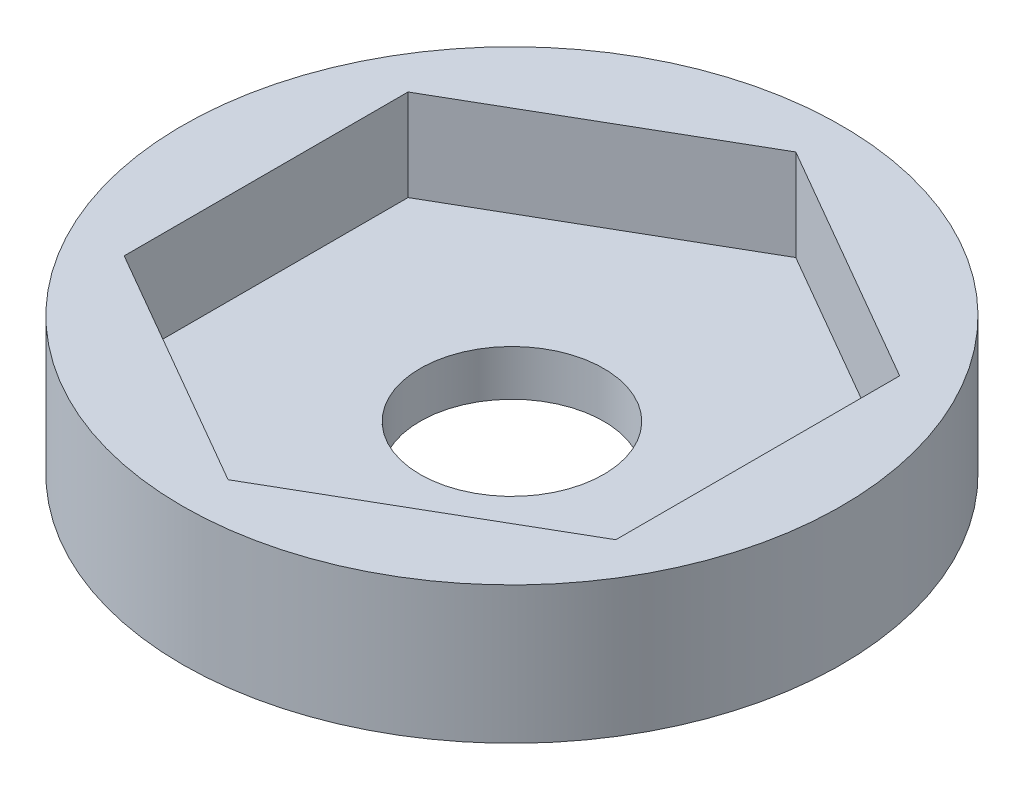
from build123d import *

# Parameters (mm, degrees)
SKETCH1_R           = 11.442176275
BOSS_EXTRUDE1_DEPTH = 3.175
BOSS_EXTRUDE2_START = -1.5875
SKETCH2_R           = 11.442176275
SKETCH2_R_2         = 3.1877
BOSS_EXTRUDE2_DEPTH = 1.5875


with BuildPart() as part:
    # Sketch1 → Boss-Extrude1 (new body)
    with BuildSketch(Plane(origin=(0, 0, 0), x_dir=(1, 0, 0), z_dir=(0, 1, 0))):
        Circle(SKETCH1_R)
        Polygon((8.5344, 4.927338137), (0, 9.854676275), (-8.5344, 4.927338137), (-8.5344, -4.927338137), (0, -9.854676275), (8.5344, -4.927338137), align=None, mode=Mode.SUBTRACT)
    extrude(amount=BOSS_EXTRUDE1_DEPTH)

    # Sketch2 → Boss-Extrude2 (add)
    with BuildSketch(Plane(origin=(0, 0, 0), x_dir=(1, 0, 0), z_dir=(0, 1, 0)).offset(BOSS_EXTRUDE2_START)):
        Circle(SKETCH2_R)
        Circle(SKETCH2_R_2, mode=Mode.SUBTRACT)
    extrude(amount=BOSS_EXTRUDE2_DEPTH)


solid = part.part
